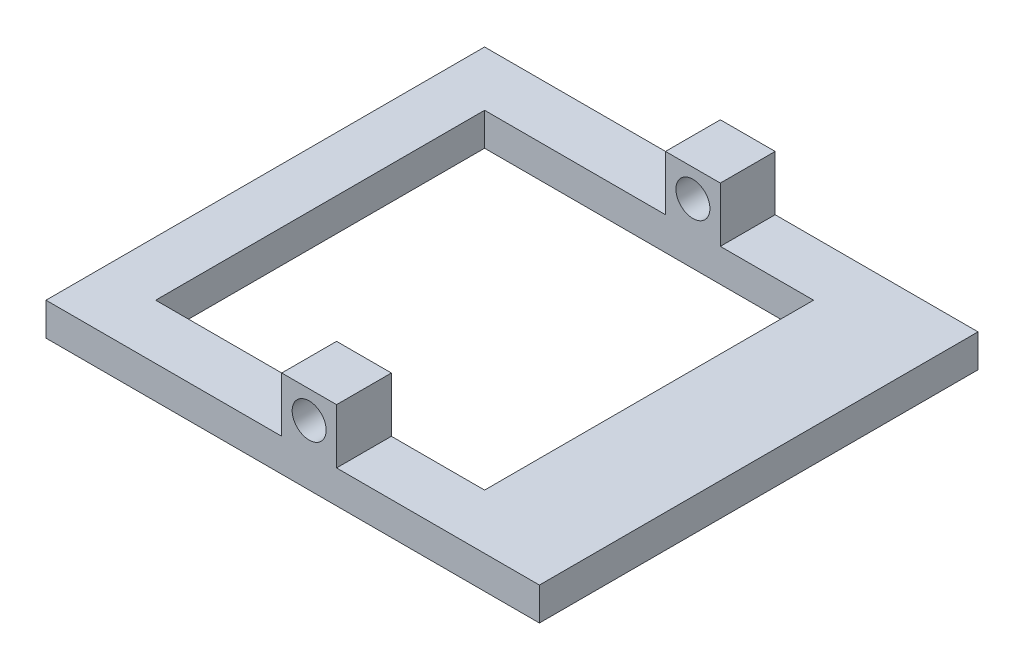
from build123d import *

# Parameters (mm, degrees)
SKETCH_1_W          = 45
SKETCH_1_H          = 40
SKETCH_1_W_2        = 30
SKETCH_1_H_2        = 30
EXTRUDE_2_DEPTH     = 3
CUT_EXTRUDE_2_DEPTH = 30
SKETCH_3_W          = 5
SKETCH_3_H          = 5
SKETCH_3_R          = 1.55
EXTRUDE_3_DEPTH     = 5


with BuildPart() as part:
    # 草图1 → 凸台-拉伸2 (new body)
    with BuildSketch(Plane(origin=(0, 0, 0), x_dir=(1, 0, 0), z_dir=(0, 1, 0))):
        Rectangle(SKETCH_1_W, SKETCH_1_H)
        with Locations((-2.5, 0)):
            Rectangle(SKETCH_1_W_2, SKETCH_1_H_2, mode=Mode.SUBTRACT)
    extrude(amount=EXTRUDE_2_DEPTH)

    # 草图2 → 切除-拉伸2 (cut)
    with BuildSketch(Plane.XY.offset(-15)):
        Polygon((12.5, 0), (15.5, 0), (15.5, 2.196152423), (12.5, 3), align=None)
    extrude(amount=CUT_EXTRUDE_2_DEPTH, mode=Mode.SUBTRACT)

    # 草图3 → 凸台-拉伸3 (add)
    with BuildSketch(Plane.XY.offset(20)):
        with Locations((1.5, 5.5)):
            Rectangle(SKETCH_3_W, SKETCH_3_H)
        with Locations((1.5, 5.5)):
            Circle(SKETCH_3_R, mode=Mode.SUBTRACT)
    extrude_3 = extrude(amount=-EXTRUDE_3_DEPTH)

    # 镜向2: 凸台-拉伸3 across plane
    add(extrude_3.mirror(Plane(origin=(0, 0, 0), x_dir=(1, 0, 0), z_dir=(0, 0, -1))))


solid = part.part
